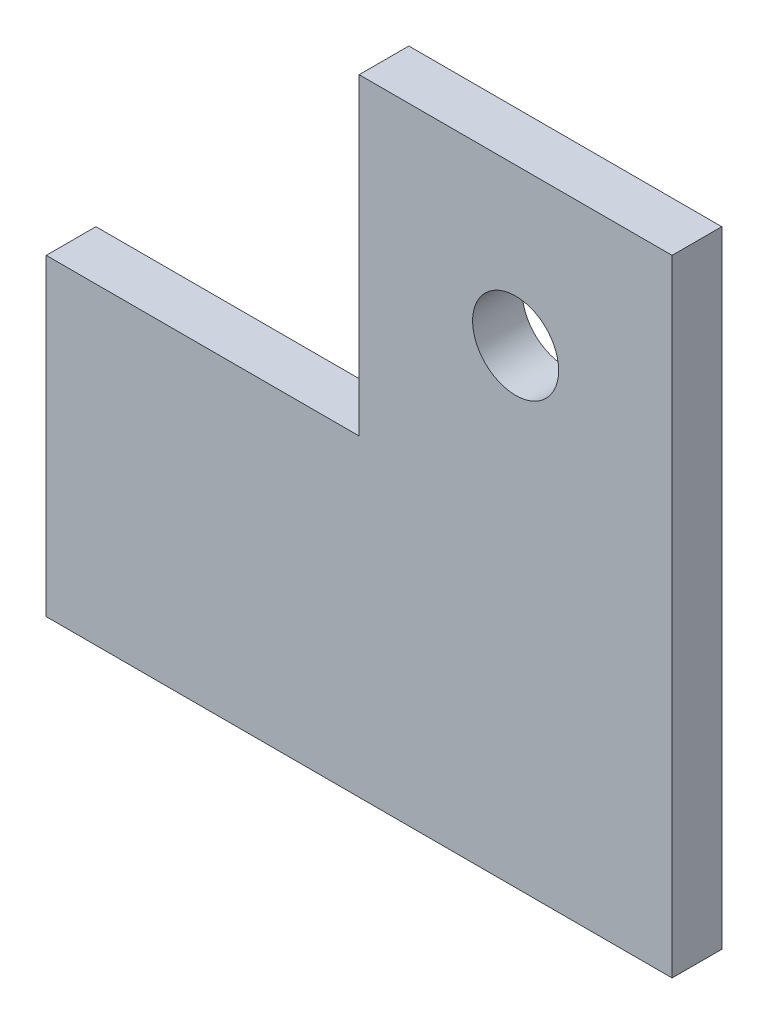
from build123d import *

# Parameters (mm, degrees)
BOSS_EXTRUDE1_DEPTH = 3.175
CUT_EXTRUDE1_REACH  = 5.175
SKETCH2_R           = 2.75


with BuildPart() as part:
    # Sketch1 → Boss-Extrude1 (new body)
    with BuildSketch(Plane.XY):
        Polygon((0, 0), (20, 0), (20, 20), (40, 20), (40, -20), (0, -20), align=None)
    extrude(amount=BOSS_EXTRUDE1_DEPTH)

    # Sketch2 → Cut-Extrude1 (cut, up to next)
    with BuildSketch(Plane.XY.offset(3.175), mode=Mode.PRIVATE) as cut_extrude1_sk1:
        with Locations((30, 10)):
            Circle(SKETCH2_R)
    cut_extrude1_tool1 = extrude(cut_extrude1_sk1.sketch, amount=-CUT_EXTRUDE1_REACH, mode=Mode.PRIVATE) & part.part
    add(cut_extrude1_tool1.solids().sort_by_distance((30, 10, 3.175))[0], mode=Mode.SUBTRACT)


solid = part.part
